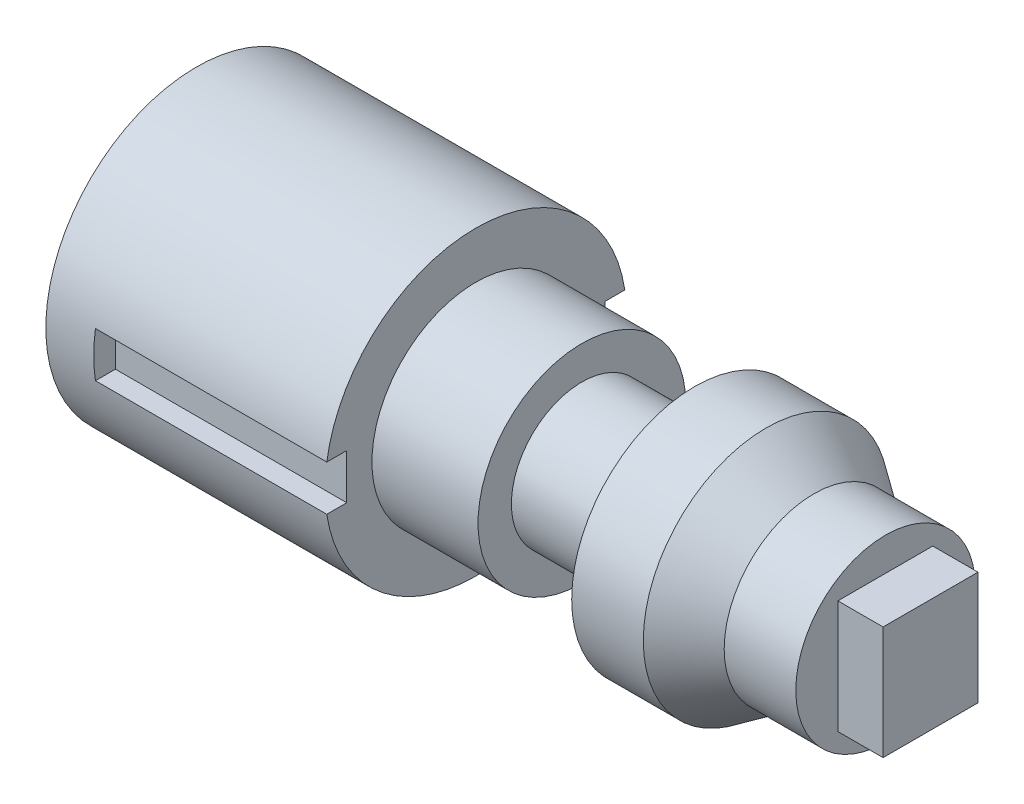
from build123d import *

# Parameters (mm, degrees)
SKETCH2_W           = 17.886691146
SKETCH2_H           = 2.175460001
CUT_EXTRUDE1_DEPTH  = 1.5
SKETCH3_W           = 6.296857424
SKETCH3_H           = 7.509086661
BOSS_EXTRUDE1_DEPTH = 3


with BuildPart() as part:
    # Sketch1 → Revolve1 (revolve)
    with BuildSketch(Plane(origin=(0, 0, 0), x_dir=(1, 0, 0), z_dir=(0, 1, 0))):
        Polygon((0, 0), (0, 10), (18.52566279, 10), (18.52566279, 6.890240487), (25.563295531, 6.890240487), (25.563295531, 4.677528689), (33.040780318, 4.677528689), (33.040780318, 8.152621406), (37.791182418, 8.152621406), (40.958117151, 5.953361174), (45.708519251, 5.953361174), (45.708519251, 0), align=None)
    revolve(axis=Axis((45.708519251, 0, 0), (-1, 0, 0)))

    # Sketch2 → Cut-Extrude1 (cut, symmetric)
    with BuildSketch(Plane(origin=(0, 0, 0), x_dir=(1, 0, 0), z_dir=(0, 1, 0))):
        with Locations((12.122244938, 9.650117441)):
            Rectangle(SKETCH2_W, SKETCH2_H)
        with Locations((12.122244938, -9.650117441)):
            Rectangle(SKETCH2_W, SKETCH2_H)
    extrude(amount=CUT_EXTRUDE1_DEPTH, both=True, mode=Mode.SUBTRACT)

    # Sketch3 → Boss-Extrude1 (add)
    with BuildSketch(Plane(origin=(45.708519251, 0, 0), x_dir=(0, 0, -1), z_dir=(1, 0, 0))):
        with Locations((-0.012160705, -0.001203589)):
            Rectangle(SKETCH3_W, SKETCH3_H)
    extrude(amount=BOSS_EXTRUDE1_DEPTH)


solid = part.part
